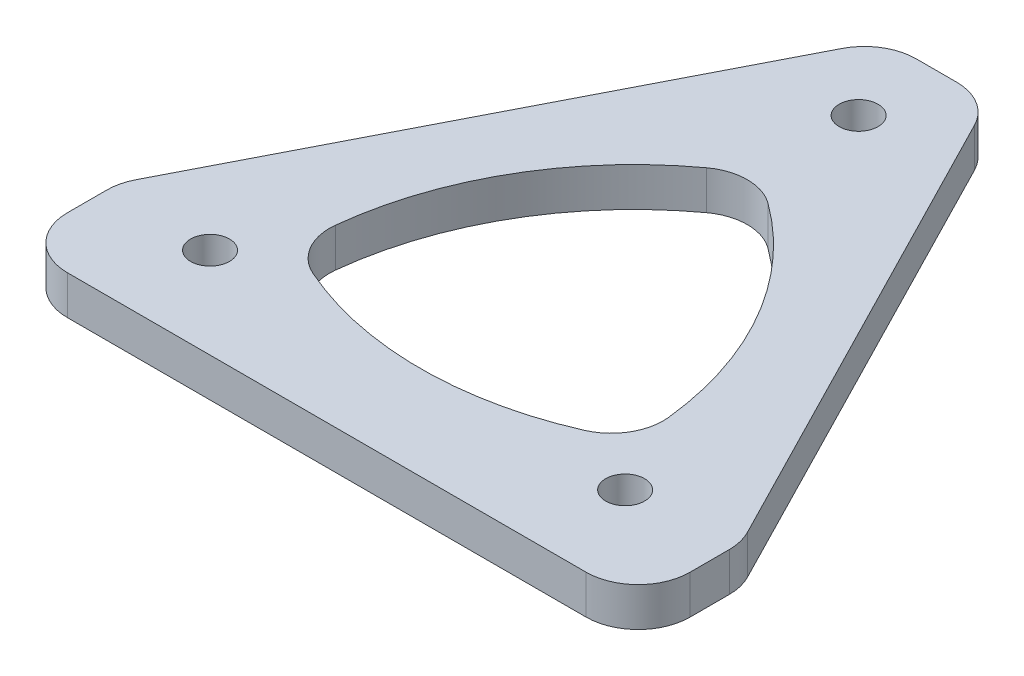
from build123d import *

# Parameters (mm, degrees)
SKETCH1_R           = 1.5
BOSS_EXTRUDE1_DEPTH = 3
CUT_EXTRUDE1_DEPTH  = 3
FILLET1_R           = 4


with BuildPart() as part:
    # Sketch1 → Boss-Extrude1 (new body)
    with BuildSketch(Plane(origin=(0, 0, 0), x_dir=(1, 0, 0), z_dir=(0, 1, 0))):
        with BuildLine():
            Line((0, 0), (-20, 0))
            ThreePointArc((-20, 0), (-22.828427125, 1.171572875), (-24, 4))
            Line((-24, 4), (-24, 7.0341572))
            ThreePointArc((-24, 7.0341572), (-23.888256641, 7.97301837), (-23.559269851, 8.85942379))
            Line((-23.559269851, 8.85942379), (-5.115247902, 44.82526659))
            ThreePointArc((-5.115247902, 44.82526659), (-3.641515588, 46.413287738), (-1.555978051, 47))
            Line((-1.555978051, 47), (1.555978051, 47))
            ThreePointArc((1.555978051, 47), (3.641515588, 46.413287738), (5.115247902, 44.82526659))
            Line((5.115247902, 44.82526659), (23.559269851, 8.85942379))
            ThreePointArc((23.559269851, 8.85942379), (23.888256641, 7.97301837), (24, 7.0341572))
            Line((24, 7.0341572), (24, 4))
            ThreePointArc((24, 4), (22.828427125, 1.171572875), (20, 0))
            Line((20, 0), (0, 0))
        make_face()
        with Locations((-16, 7)):
            Circle(SKETCH1_R, mode=Mode.SUBTRACT)
        with Locations((0, 41)):
            Circle(SKETCH1_R, mode=Mode.SUBTRACT)
        with Locations((16, 7)):
            Circle(SKETCH1_R, mode=Mode.SUBTRACT)
    extrude(amount=BOSS_EXTRUDE1_DEPTH)

    # Sketch2 → Cut-Extrude1 (cut)
    with BuildSketch(Plane(origin=(0, 3, 0), x_dir=(1, 0, 0), z_dir=(0, 1, 0))):
        with BuildLine():
            ThreePointArc((-12.990381057, 10.690853285), (0, 7.210091171), (12.990381057, 10.690853285))
            ThreePointArc((12.990381057, 10.690853285), (9.509618943, 23.681234342), (0, 33.190853285))
            ThreePointArc((0, 33.190853285), (-9.509618943, 23.681234342), (-12.990381057, 10.690853285))
        make_face()
    extrude(amount=-CUT_EXTRUDE1_DEPTH, mode=Mode.SUBTRACT)

    # Fillet1
    fillet1_edges = [part.edges().sort_by_distance(p)[0] for p in [
        (-12.990381057, 1.5, -10.690853285),
        (0, 1.5, -33.190853285),
        (12.990381057, 1.5, -10.690853285),
    ]]
    fillet(fillet1_edges, radius=FILLET1_R)


solid = part.part
